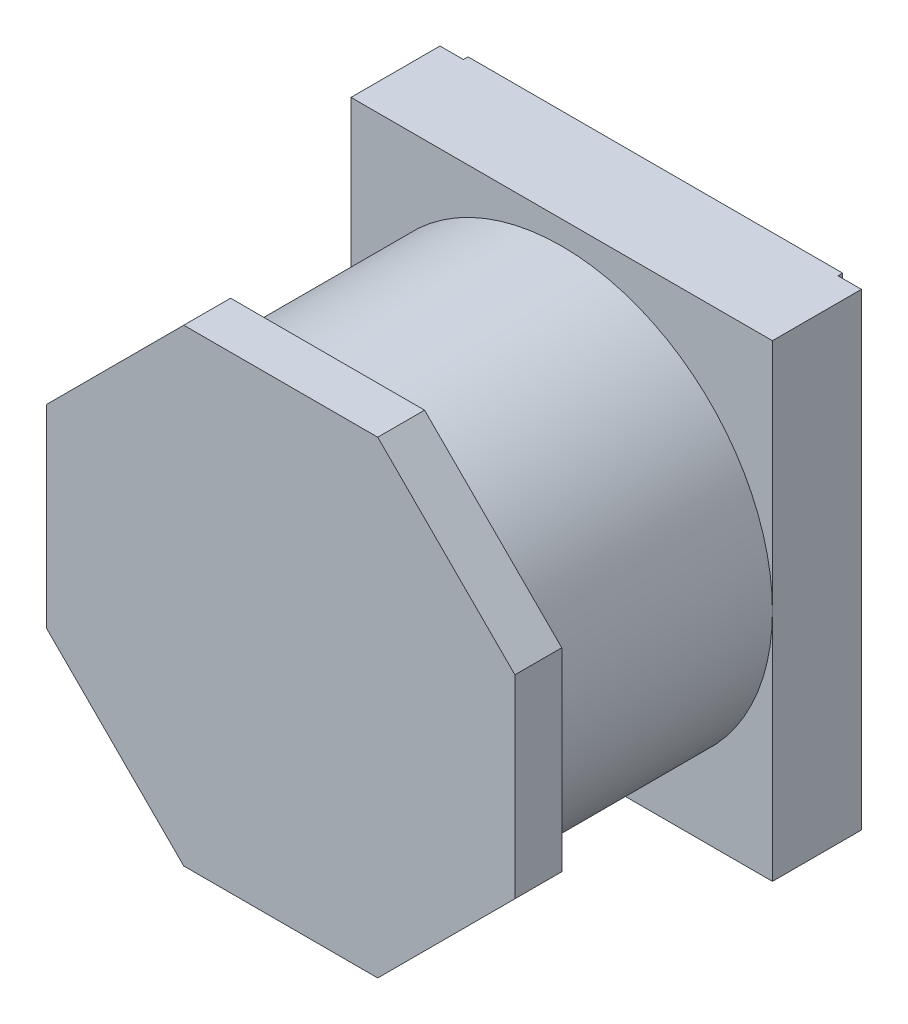
from build123d import *

# Parameters (mm, degrees)
SKETCH1_W           = 4.5
SKETCH1_H           = 5
BOSS_EXTRUDE1_DEPTH = 1
SKETCH2_R           = 2.25
BOSS_EXTRUDE2_DEPTH = 2.5
BOSS_EXTRUDE3_DEPTH = 0.5
CUT_EXTRUDE1_DEPTH  = 0.05


with BuildPart() as part:
    # Sketch1 → Boss-Extrude1 (new body)
    with BuildSketch(Plane.XY):
        with Locations((-2.25, 2.5)):
            Rectangle(SKETCH1_W, SKETCH1_H)
    extrude(amount=BOSS_EXTRUDE1_DEPTH)

    # Sketch2 → Boss-Extrude2 (add)
    with BuildSketch(Plane.XY.offset(1)):
        with Locations((-2.25, 2.5)):
            Circle(SKETCH2_R)
    extrude(amount=BOSS_EXTRUDE2_DEPTH)

    # Sketch3 → Boss-Extrude3 (add)
    with BuildSketch(Plane.XY.offset(3.5)):
        Polygon((-1.214319799, 5.000353186), (-3.285680201, 5.000353186), (-4.750353186, 3.535680201), (-4.750353186, 1.464319799), (-3.285680201, -0.000353186), (-1.214319799, -0.000353186), (0.250353186, 1.464319799), (0.250353186, 3.535680201), align=None)
    extrude(amount=BOSS_EXTRUDE3_DEPTH)

    # Sketch5 → Cut-Extrude1 (cut)
    with BuildSketch(Plane(origin=(0, 0, 0), x_dir=(-1, 0, 0), z_dir=(0, 0, -1))):
        Polygon((0.25, 5), (0, 5), (0, 0), (0.25, 0), (0.25, 1.25), (4.25, 1.25), (4.25, 0), (4.5, 0), (4.5, 5), (4.25, 5), (4.25, 3.75), (0.25, 3.75), align=None)
    extrude(amount=-CUT_EXTRUDE1_DEPTH, mode=Mode.SUBTRACT)


solid = part.part
